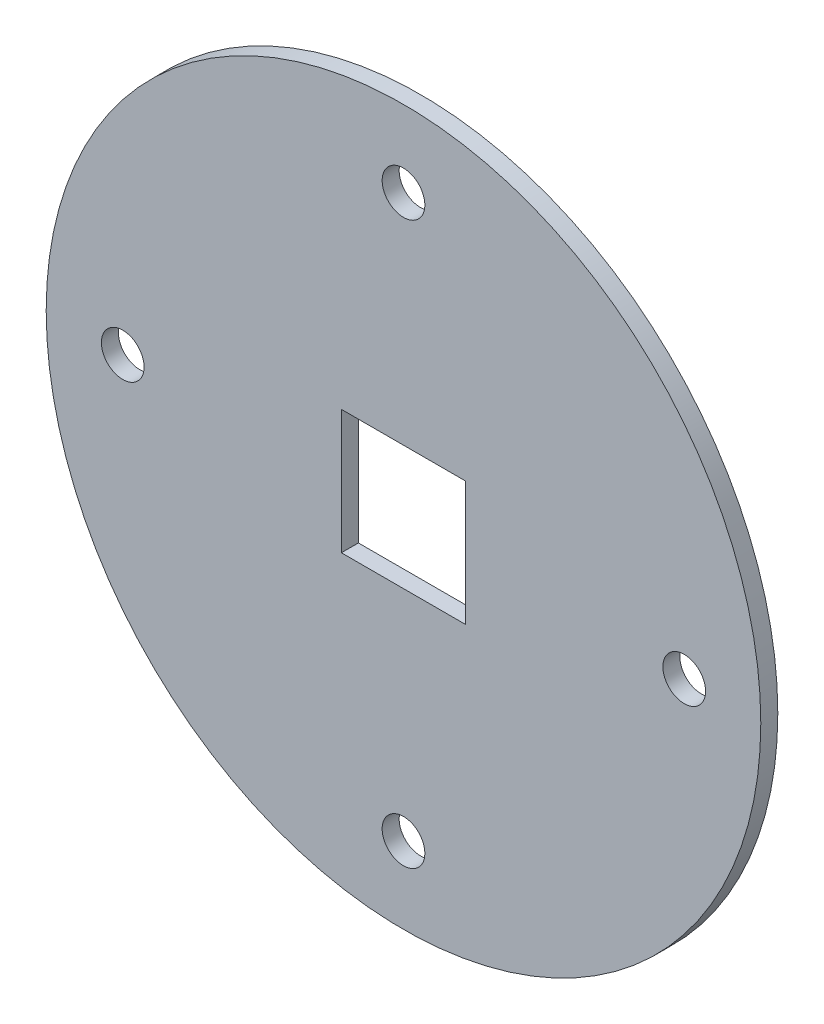
from build123d import *

# Parameters (mm, degrees)
IZIM1_R                     = 210
IZIM1_R_2                   = 12.55
IZIM1_W                     = 73
IZIM1_H                     = 73
Y_KSEKLIK_EKSTR_ZYON1_DEPTH = 10


with BuildPart() as part:
    # Çizim1 → Yükseklik-Ekstrüzyon1 (new body)
    with BuildSketch(Plane.XY):
        Circle(IZIM1_R)
        with Locations((0, 165)):
            Circle(IZIM1_R_2, mode=Mode.SUBTRACT)
        with Locations((165, 0)):
            Circle(IZIM1_R_2, mode=Mode.SUBTRACT)
        with Locations((0, -165)):
            Circle(IZIM1_R_2, mode=Mode.SUBTRACT)
        with Locations((-165, 0)):
            Circle(IZIM1_R_2, mode=Mode.SUBTRACT)
        Rectangle(IZIM1_W, IZIM1_H, mode=Mode.SUBTRACT)
    extrude(amount=Y_KSEKLIK_EKSTR_ZYON1_DEPTH)


solid = part.part
